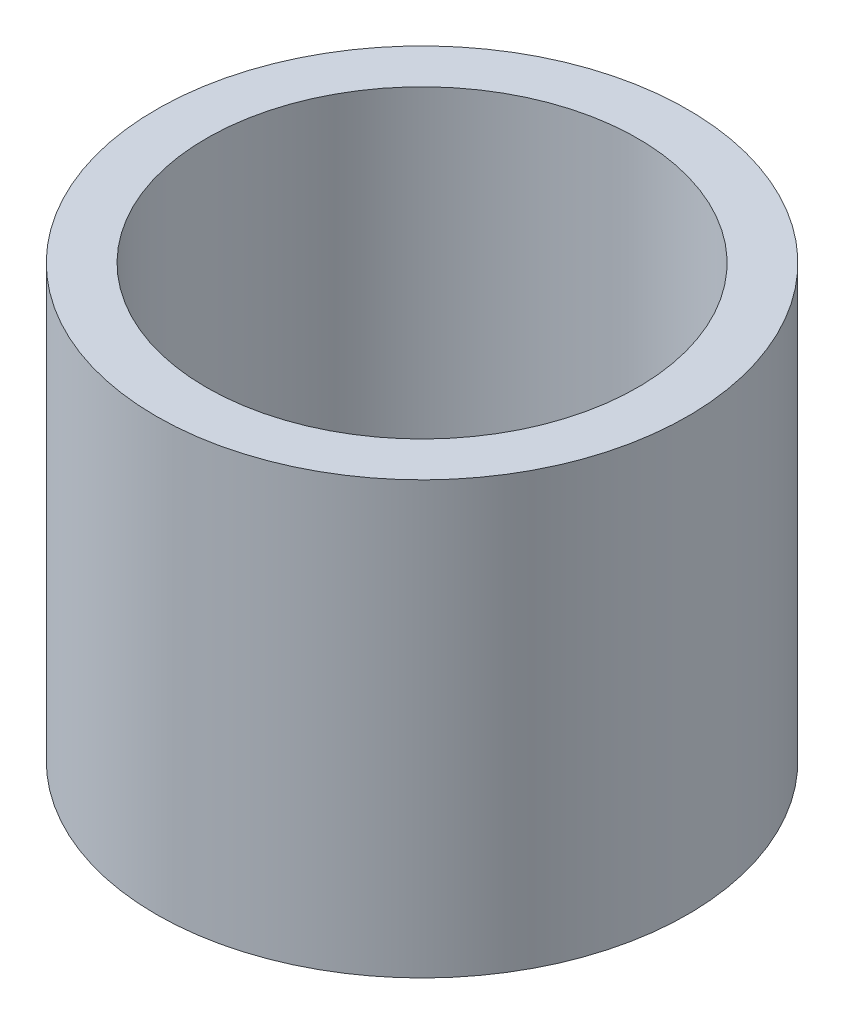
from build123d import *

# Parameters (mm, degrees)
ESQUISSE1_W = 0.29
ESQUISSE1_H = 2.5


with BuildPart() as part:
    # Esquisse1 → Révolution1 (revolve)
    with BuildSketch(Plane.XY):
        with Locations((1.395, 1.25)):
            Rectangle(ESQUISSE1_W, ESQUISSE1_H)
    revolve(axis=Axis((0, 1.835774822, 0), (0, -1, 0)))


solid = part.part
